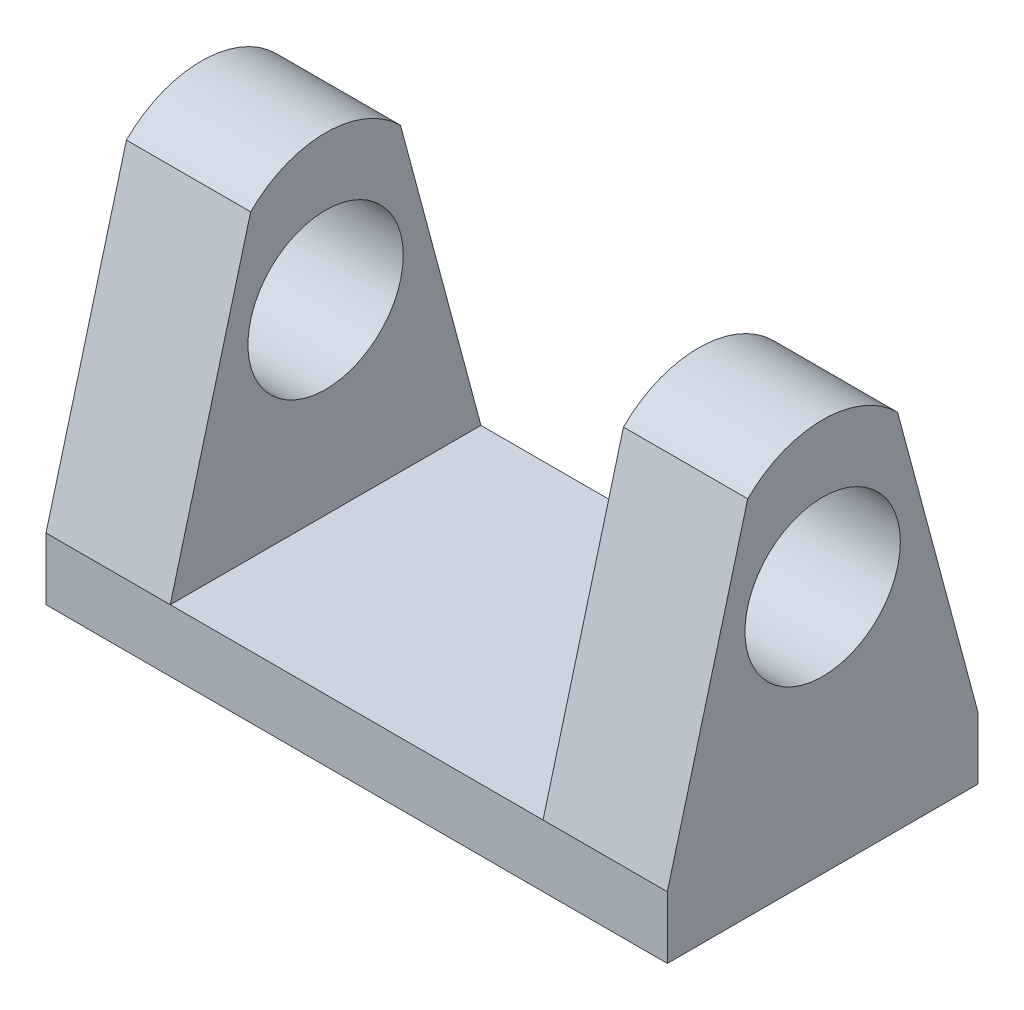
from build123d import *

# Parameters (mm, degrees)
SKETCH1_W           = 25.4
SKETCH1_H           = 12.7
BOSS_EXTRUDE1_DEPTH = 2.54
BOSS_EXTRUDE2_DEPTH = 5.08
SKETCH3_R           = 3.175
CUT_EXTRUDE1_DEPTH  = 26.4


with BuildPart() as part:
    # Sketch1 → Boss-Extrude1 (new body)
    with BuildSketch(Plane(origin=(0, 0, 0), x_dir=(1, 0, 0), z_dir=(0, 1, 0))):
        Rectangle(SKETCH1_W, SKETCH1_H)
    extrude(amount=BOSS_EXTRUDE1_DEPTH)

    # Sketch2 → Boss-Extrude2 (add)
    with BuildSketch(Plane(origin=(12.7, 0, 0), x_dir=(0, 0, -1), z_dir=(1, 0, 0))):
        with BuildLine():
            Line((-6.35, 2.54), (-3.062998127, 14.807257994))
            ThreePointArc((-3.062998127, 14.807257994), (0, 16.07599336), (3.062998127, 14.807257994))
            Line((3.062998127, 14.807257994), (6.35, 2.54))
            Line((6.35, 2.54), (-6.35, 2.54))
        make_face()
    boss_extrude2 = extrude(amount=-BOSS_EXTRUDE2_DEPTH)

    # Mirror1: Boss-Extrude2 across plane
    add(boss_extrude2.mirror(Plane(origin=(0, 0, 0), x_dir=(0, 0, 1), z_dir=(1, 0, 0))))

    # Sketch3 → Cut-Extrude1 (cut, through all)
    with BuildSketch(Plane(origin=(12.7, 0, 0), x_dir=(0, 0, -1), z_dir=(1, 0, 0))):
        with Locations((0, 10.16)):
            Circle(SKETCH3_R)
    extrude(amount=-CUT_EXTRUDE1_DEPTH, mode=Mode.SUBTRACT)


solid = part.part
